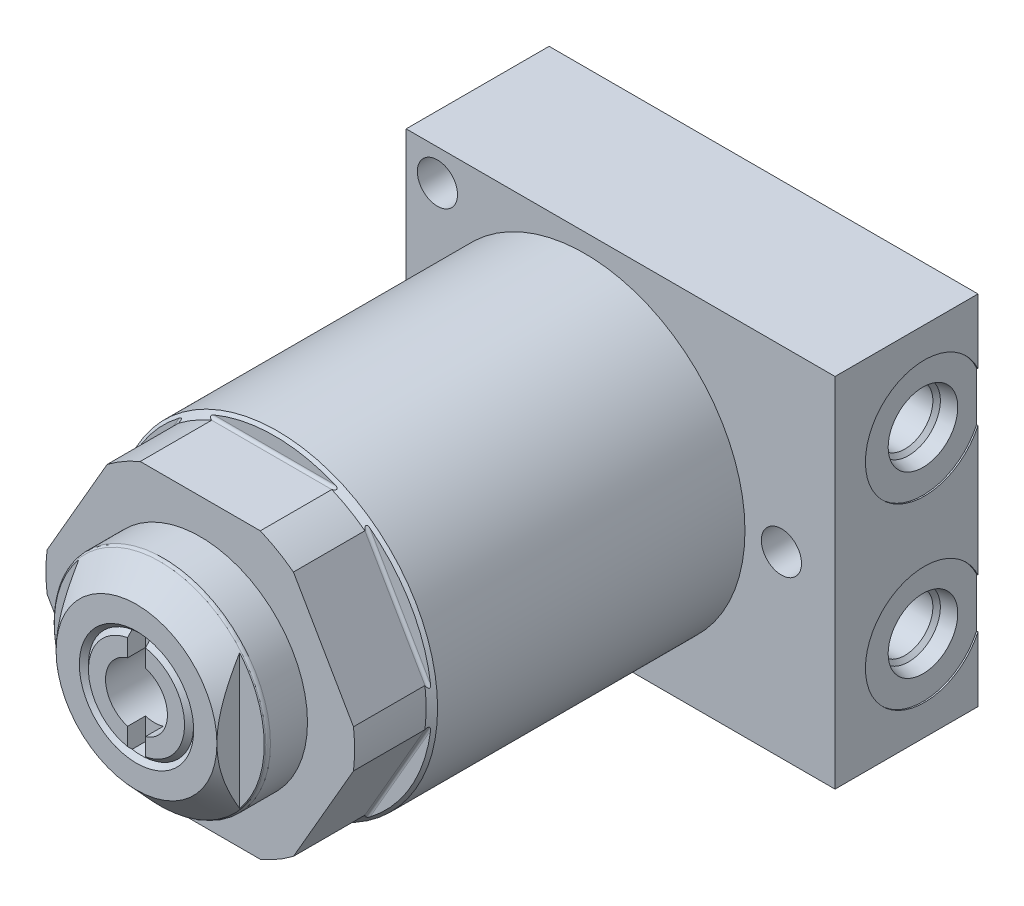
from build123d import *

# Parameters (mm, degrees)
SKETCH1_R           = 28.448
EXTRUDE1_DEPTH      = 82.55
CUT_EXTRUDE1_DEPTH  = 34.1376
SKETCH13_W          = 11.3284
SKETCH13_H          = 19.05
S2D0011_W           = 5.4991
S2D0011_H           = 16.002
SKETCH16_W          = 76.2
SKETCH16_H          = 25.4
EXTRUDE2_DEPTH      = 31.75
EXTRUDE2_DEPTH_BACK = 31.75
SKETCH17_R          = 10.4775
CUT_EXTRUDE9_DEPTH  = 0.254
SKETCH18_R          = 10.4775
CUT_EXTRUDE10_DEPTH = 0.254
CIRPATTERN2_COUNT   = 6
HOLE1_D             = 7.1374
HOLE1_DEPTH         = 25.4
CUT_EXTRUDE11_DEPTH = 4.0386
CUT_EXTRUDE12_DEPTH = 3.175


with BuildPart() as part:
    # Sketch1 → Extrude1 (new body)
    with BuildSketch(Plane.XY):
        Circle(SKETCH1_R)
    extrude(amount=EXTRUDE1_DEPTH)

    # Sketch2 → Cut-Extrude1 (cut, symmetric)
    with BuildSketch(Plane(origin=(0, 0, 0), x_dir=(0, 0, 1), z_dir=(1, 0, 0))):
        with BuildLine():
            Line((69.342, 28.448), (69.342, 25.781))
            ThreePointArc((69.342, 25.781), (69.490789755, 25.421789755), (69.85, 25.273))
            Line((69.85, 25.273), (82.55, 25.273))
            Line((82.55, 25.273), (82.55, 28.448))
            Line((82.55, 28.448), (69.342, 28.448))
        make_face()
    cut_extrude1 = extrude(amount=CUT_EXTRUDE1_DEPTH, both=True, mode=Mode.SUBTRACT)

    # Sketch10 → Cut-Revolve1 (revolve, cut)
    with BuildSketch(Plane(origin=(0, 0, 0), x_dir=(0, 0, -1), z_dir=(1, 0, 0)), mode=Mode.PRIVATE) as cut_revolve1_sk:
        Polygon((-82.55, 27.432), (-69.85, 27.432), (-68.834, 28.448), (-82.55, 28.448), align=None)
    revolve(cut_revolve1_sk.sketch.rotate(Axis((0, 0, 83.2358), (0, 0, -1)), 90), axis=Axis((0, 0, 83.2358), (0, 0, -1)), mode=Mode.SUBTRACT)  # turned: the seam where the file's is

    # Sketch13 → Revolve1 (revolve)
    with BuildSketch(Plane(origin=(0, 0, 0), x_dir=(0, 0, -1), z_dir=(1, 0, 0)), mode=Mode.PRIVATE) as revolve1_sk:
        with Locations((-88.2142, 9.525)):
            Rectangle(SKETCH13_W, SKETCH13_H)
    revolve(revolve1_sk.sketch.rotate(Axis((0, 0, 94.44482), (0, 0, -1)), 90), axis=Axis((0, 0, 94.44482), (0, 0, -1)))  # turned: the seam where the file's is

    # S2D0011 → Cut-Revolve4 (revolve, cut)
    with BuildSketch(Plane(origin=(-5.4991, 0, 93.8784), x_dir=(-1, 0, 0), z_dir=(0, 1, 0)), mode=Mode.PRIVATE) as cut_revolve4_sk:
        with Locations((-2.74955, -8.001)):
            Rectangle(S2D0011_W, S2D0011_H)
    revolve(cut_revolve4_sk.sketch.rotate(Axis((0, 0, 39.576937479), (0, 0, 1)), 180), axis=Axis((0, 0, 39.576937479), (0, 0, 1)), mode=Mode.SUBTRACT)  # turned: the seam where the file's is

    # Sketch15 → Cut-Revolve5 (revolve, cut)
    with BuildSketch(Plane(origin=(0, 0, 0), x_dir=(0, 0, -1), z_dir=(1, 0, 0)), mode=Mode.PRIVATE) as cut_revolve5_sk:
        with BuildLine():
            Line((-93.8784, 14.2875), (-89.706615474, 18.79729325))
            ThreePointArc((-89.706615474, 18.79729325), (-89.444021381, 18.984062482), (-89.1286, 19.05))
            Line((-89.1286, 19.05), (-93.8784, 19.05))
            Line((-93.8784, 19.05), (-93.8784, 14.2875))
        make_face()
    revolve(cut_revolve5_sk.sketch.rotate(Axis((0, 0, 94.11589), (0, 0, -1)), 90), axis=Axis((0, 0, 94.11589), (0, 0, -1)), mode=Mode.SUBTRACT)  # turned: the seam where the file's is

    # Sketch16 → Extrude2 (add, two sides)
    with BuildSketch(Plane(origin=(0, 0, 0), x_dir=(-1, 0, 0), z_dir=(0, 1, 0))) as extrude2_sk:
        with Locations((-6.35, 1.524)):
            Rectangle(SKETCH16_W, SKETCH16_H)
    extrude(amount=EXTRUDE2_DEPTH)
    extrude(extrude2_sk.sketch, amount=-EXTRUDE2_DEPTH_BACK)

    # Sketch17 → Cut-Extrude9 (cut)
    with BuildSketch(Plane(origin=(44.45, 0, 0), x_dir=(0, 0, -1), z_dir=(1, 0, 0))):
        with Locations((1.651, -15.875)):
            Circle(SKETCH17_R)
    extrude(amount=-CUT_EXTRUDE9_DEPTH, mode=Mode.SUBTRACT)

    # Sketch18 → Cut-Extrude10 (cut)
    with BuildSketch(Plane(origin=(44.45, 0, 0), x_dir=(0, 0, -1), z_dir=(1, 0, 0))):
        with Locations((1.651, 15.875)):
            Circle(SKETCH18_R)
    extrude(amount=-CUT_EXTRUDE10_DEPTH, mode=Mode.SUBTRACT)

    # S2D0002 → Cut-Revolve6 (revolve, cut)
    with BuildSketch(Plane(origin=(44.196, -15.875, -1.651), x_dir=(0, -1, 0), z_dir=(0, 0, 1)), mode=Mode.PRIVATE) as cut_revolve6_sk:
        Polygon((0, 0), (6.1849, 0), (5.642306865, -2.5527), (4.9784, -3.216606865), (4.9784, -17.272), (0, -17.272), align=None)
    revolve(cut_revolve6_sk.sketch.rotate(Axis((26.0604, -15.875, -1.651), (1, 0, 0)), 270), axis=Axis((26.0604, -15.875, -1.651), (1, 0, 0)), mode=Mode.SUBTRACT)  # turned: the seam where the file's is

    # S2D0001 → Cut-Revolve7 (revolve, cut)
    with BuildSketch(Plane(origin=(44.196, 15.875, -1.651), x_dir=(0, -1, 0), z_dir=(0, 0, 1)), mode=Mode.PRIVATE) as cut_revolve7_sk:
        Polygon((0, 0), (6.1849, 0), (5.642306865, -2.5527), (4.9784, -3.216606865), (4.9784, -17.272), (0, -17.272), align=None)
    revolve(cut_revolve7_sk.sketch.rotate(Axis((26.0604, 15.875, -1.651), (1, 0, 0)), 270), axis=Axis((26.0604, 15.875, -1.651), (1, 0, 0)), mode=Mode.SUBTRACT)  # turned: the seam where the file's is

    # CirPattern2: Cut-Extrude1 ×6 about axis
    cirpattern2_axis = Axis((0, 0, 0), (0, 0, 1))
    for i in range(1, CIRPATTERN2_COUNT):
        add(cut_extrude1.rotate(cirpattern2_axis, i * 360 / CIRPATTERN2_COUNT), mode=Mode.SUBTRACT)

    # Hole1
    with Locations(Plane.XY.offset(14.224)):
        with Locations((-26.1874, -26.1874), (34.925, 0), (-26.1874, 26.1874)):
            Hole(HOLE1_D / 2, depth=HOLE1_DEPTH)

    # Sketch23 → Cut-Extrude11 (cut)
    with BuildSketch(Plane.XY.offset(93.8784)):
        with BuildLine():
            Line((-14.2875, 12.600390619), (-14.2875, -12.600390619))
            ThreePointArc((-14.2875, -12.600390619), (-19.05, 0), (-14.2875, 12.600390619))
        make_face()
        with BuildLine():
            Line((14.2875, 12.600390619), (14.2875, -12.600390619))
            ThreePointArc((14.2875, -12.600390619), (19.05, 0), (14.2875, 12.600390619))
        make_face()
    extrude(amount=-CUT_EXTRUDE11_DEPTH, mode=Mode.SUBTRACT)

    # Sketch25 → Cut-Revolve8 (revolve, cut)
    with BuildSketch(Plane(origin=(0, 0, 0), x_dir=(0, 0, -1), z_dir=(1, 0, 0)), mode=Mode.PRIVATE) as cut_revolve8_sk:
        Polygon((-93.8784, 8.5344), (-93.0656, 9.3472), (-93.8784, 10.16), align=None)
    revolve(cut_revolve8_sk.sketch.rotate(Axis((0, 0, 93.13164), (0, 0, -1)), 90), axis=Axis((0, 0, 93.13164), (0, 0, -1)), mode=Mode.SUBTRACT)  # turned: the seam where the file's is

    # Sketch26 → Cut-Extrude12 (cut)
    with BuildSketch(Plane.XY.offset(93.8784)):
        with BuildLine():
            Line((-1.5875, 9.211405517), (-1.5875, -9.211405517))
            ThreePointArc((-1.5875, -9.211405517), (0, -9.3472), (1.5875, -9.211405517))
            Line((1.5875, -9.211405517), (1.5875, 9.211405517))
            ThreePointArc((1.5875, 9.211405517), (0, 9.3472), (-1.5875, 9.211405517))
        make_face()
    extrude(amount=-CUT_EXTRUDE12_DEPTH, mode=Mode.SUBTRACT)


solid = part.part
